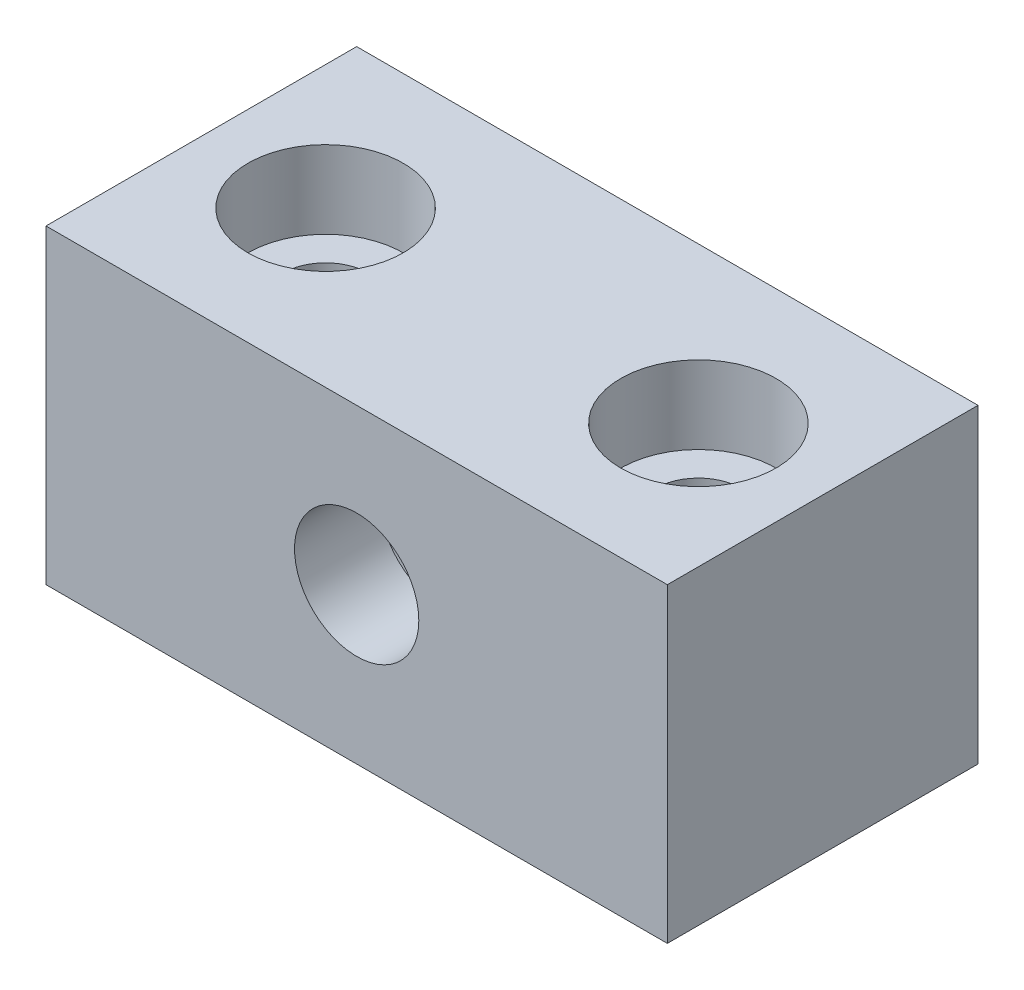
from build123d import *

# Parameters (mm, degrees)
SKETCH1_W           = 40
SKETCH1_H           = 20
BOSS_EXTRUDE1_DEPTH = 20
SKETCH2_R           = 2.75
CUT_EXTRUDE1_DEPTH  = 21
SKETCH3_R           = 5
CUT_EXTRUDE2_DEPTH  = 5
SKETCH4_R           = 4
CUT_EXTRUDE3_DEPTH  = 5.5
SKETCH5_R           = 4
CUT_EXTRUDE4_DEPTH  = 5.5
SKETCH6_R           = 3.5
CUT_EXTRUDE5_DEPTH  = 15.5


with BuildPart() as part:
    # Sketch1 → Boss-Extrude1 (new body)
    with BuildSketch(Plane.XY):
        with Locations((20, 10)):
            Rectangle(SKETCH1_W, SKETCH1_H)
    extrude(amount=BOSS_EXTRUDE1_DEPTH)

    # Sketch2 → Cut-Extrude1 (cut, through all)
    with BuildSketch(Plane(origin=(0, 20, 0), x_dir=(1, 0, 0), z_dir=(0, 1, 0))):
        with Locations((8, -10)):
            Circle(SKETCH2_R)
        with Locations((32, -10)):
            Circle(SKETCH2_R)
    extrude(amount=-CUT_EXTRUDE1_DEPTH, mode=Mode.SUBTRACT)

    # Sketch3 → Cut-Extrude2 (cut)
    with BuildSketch(Plane(origin=(0, 20, 0), x_dir=(1, 0, 0), z_dir=(0, 1, 0))):
        with Locations((8, -10)):
            Circle(SKETCH3_R)
        with Locations((32, -10)):
            Circle(SKETCH3_R)
    extrude(amount=-CUT_EXTRUDE2_DEPTH, mode=Mode.SUBTRACT)

    # Sketch4 → Cut-Extrude3 (cut)
    with BuildSketch(Plane.XY.offset(20)):
        with Locations((20, 10)):
            Circle(SKETCH4_R)
    extrude(amount=-CUT_EXTRUDE3_DEPTH, mode=Mode.SUBTRACT)

    # Sketch5 → Cut-Extrude4 (cut)
    with BuildSketch(Plane(origin=(0, 0, 0), x_dir=(-1, 0, 0), z_dir=(0, 0, -1))):
        with Locations((-20, 10)):
            Circle(SKETCH5_R)
    extrude(amount=-CUT_EXTRUDE4_DEPTH, mode=Mode.SUBTRACT)

    # Sketch6 → Cut-Extrude5 (cut, through all)
    with BuildSketch(Plane.XY.offset(14.5)):
        with Locations((20, 10)):
            Circle(SKETCH6_R)
    extrude(amount=-CUT_EXTRUDE5_DEPTH, mode=Mode.SUBTRACT)


solid = part.part
